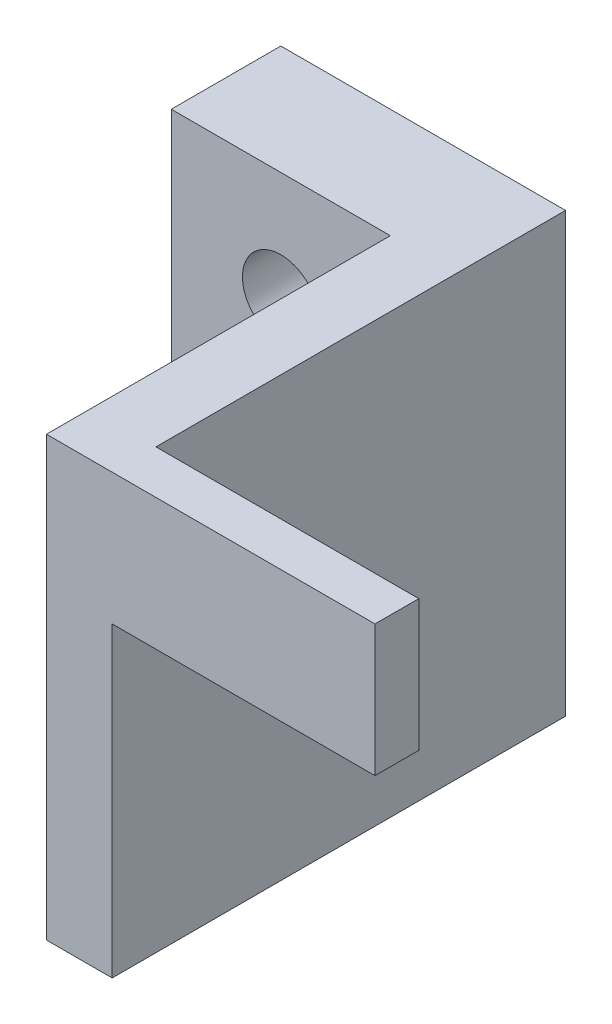
from build123d import *

# Parameters (mm, degrees)
SKETCH_1_W          = 13
SKETCH_1_H          = 20
EXTRUDE_1_DEPTH     = 5
SKETCH_3_W          = 3
SKETCH_3_H          = 20
EXTRUDE_2_DEPTH     = 15.7
SKETCH_4_W          = 2
SKETCH_4_H          = 20
EXTRUDE_3_DEPTH     = 15
SKETCH_5_W          = 12
SKETCH_5_H          = 14
CUT_EXTRUDE_1_DEPTH = 21.7
SKETCH_6_R          = 1.75
CUT_EXTRUDE_2_DEPTH = 6


with BuildPart() as part:
    # 草图1 → 凸台-拉伸1 (new body)
    with BuildSketch(Plane.XY):
        with Locations((6.5, 10)):
            Rectangle(SKETCH_1_W, SKETCH_1_H)
    extrude(amount=EXTRUDE_1_DEPTH)

    # 草图3 → 凸台-拉伸2 (add)
    with BuildSketch(Plane.XY.offset(5)):
        with Locations((11.5, 10)):
            Rectangle(SKETCH_3_W, SKETCH_3_H)
    extrude(amount=EXTRUDE_2_DEPTH)

    # 草图4 → 凸台-拉伸3 (add)
    with BuildSketch(Plane.ZY.offset(-10)):
        with Locations((19.7, 10)):
            Rectangle(SKETCH_4_W, SKETCH_4_H)
    extrude(amount=-EXTRUDE_3_DEPTH)

    # 草图5 → 切除-拉伸1 (cut, through all)
    with BuildSketch(Plane.XY.offset(20.7)):
        with Locations((19, 7)):
            Rectangle(SKETCH_5_W, SKETCH_5_H)
    extrude(amount=-CUT_EXTRUDE_1_DEPTH, mode=Mode.SUBTRACT)

    # 草图6 → 切除-拉伸2 (cut, through all)
    with BuildSketch(Plane.XY.offset(5)):
        with Locations((5, 15)):
            Circle(SKETCH_6_R)
        with Locations((5, 5)):
            Circle(SKETCH_6_R)
    extrude(amount=-CUT_EXTRUDE_2_DEPTH, mode=Mode.SUBTRACT)


solid = part.part
